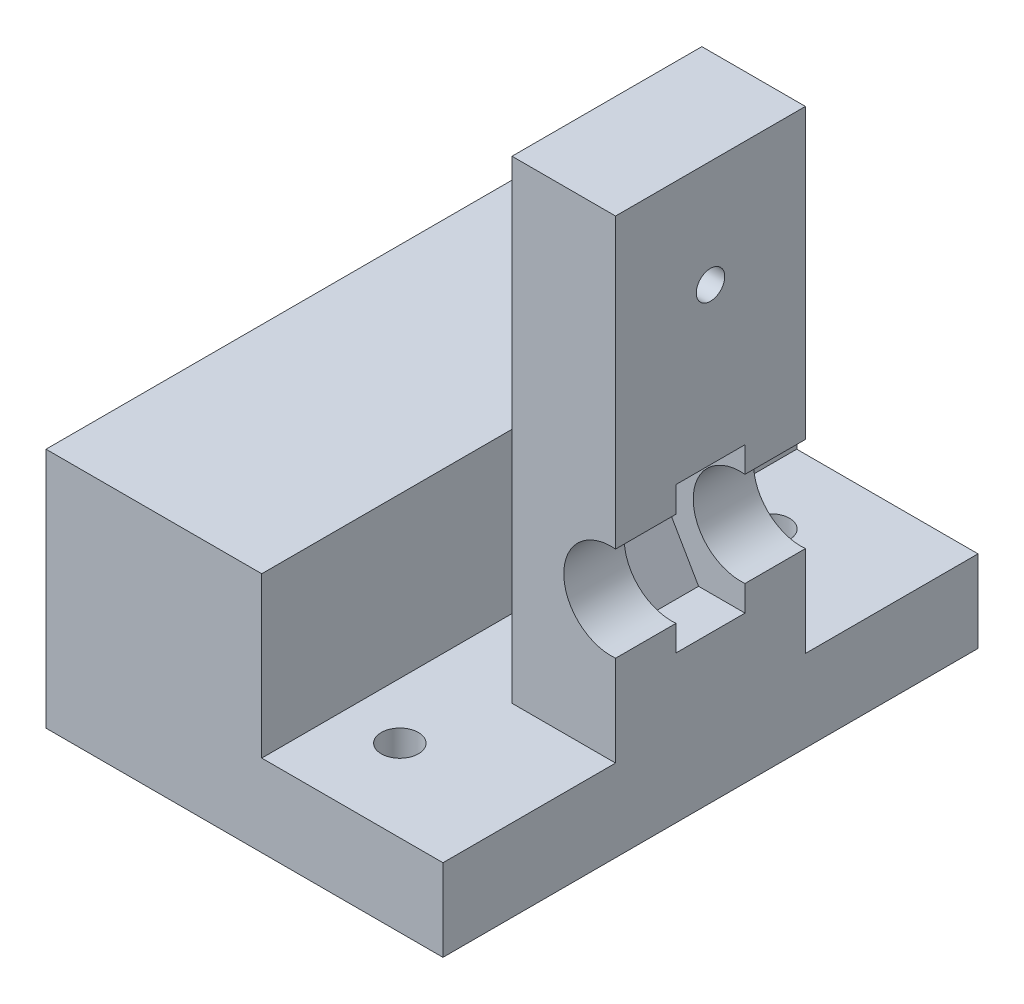
from build123d import *

# Parameters (mm, degrees)
SKETCH_1_W          = 23
SKETCH_1_H          = 64.4
EXTRUDE_1_DEPTH     = 8
SKETCH_3_W          = 23
SKETCH_3_H          = 64.4
SKETCH_3_R          = 5.5
EXTRUDE_2_DEPTH     = 7
SKETCH_4_W          = 23
SKETCH_4_H          = 64.4
SKETCH_4_R          = 5.5
EXTRUDE_3_DEPTH     = 7
SKETCH_5_R          = 1.65
CUT_EXTRUDE_1_DEPTH = 24
SKETCH_6_W          = 22
SKETCH_6_H          = 64.4
CUT_EXTRUDE_2_DEPTH = 11
EXTRUDE_4_DEPTH     = 9.5
SKETCH_8_R          = 2.15
CUT_EXTRUDE_3_DEPTH = 10.5
SKETCH_9_R          = 4.75
CUT_EXTRUDE_4_DEPTH = 3.5
SKETCH_10_W         = 25
SKETCH_10_H         = 62
EXTRUDE_5_DEPTH     = 18.5


with BuildPart() as part:
    # 草圖1 → 填料-伸長1 (new body)
    with BuildSketch(Plane.XY):
        with Locations((-0.36746988, -27.579314659)):
            Rectangle(SKETCH_1_W, SKETCH_1_H)
        Polygon((9.38974967, -34.279314659), (4.511139895, -25.829314659), (-5.246079654, -25.829314659), (-10.124689429, -34.279314659), (-5.246079654, -42.729314659), (4.511139895, -42.729314659), align=None, mode=Mode.SUBTRACT)
    extrude(amount=EXTRUDE_1_DEPTH)

    # 草圖3 → 填料-伸長2 (add)
    with BuildSketch(Plane.XY.offset(8)):
        with Locations((-0.36746988, -27.579314659)):
            Rectangle(SKETCH_3_W, SKETCH_3_H)
        with Locations((-0.36746988, -34.279314659)):
            Circle(SKETCH_3_R, mode=Mode.SUBTRACT)
    extrude(amount=EXTRUDE_2_DEPTH)

    # 草圖4 → 填料-伸長3 (add)
    with BuildSketch(Plane(origin=(0, 0, 0), x_dir=(-1, 0, 0), z_dir=(0, 0, -1))):
        with Locations((0.36746988, -27.579314659)):
            Rectangle(SKETCH_4_W, SKETCH_4_H)
        with Locations((0.36746988, -34.279314659)):
            Circle(SKETCH_4_R, mode=Mode.SUBTRACT)
    extrude(amount=EXTRUDE_3_DEPTH)

    # 草圖5 → 除料-伸長1 (cut, through all)
    with BuildSketch(Plane(origin=(11.13253012, 0, 0), x_dir=(0, 0, -1), z_dir=(1, 0, 0))):
        with Locations((-4, -7.779314659)):
            Circle(SKETCH_5_R)
    extrude(amount=-CUT_EXTRUDE_1_DEPTH, mode=Mode.SUBTRACT)

    # 草圖6 → 除料-伸長2 (cut)
    with BuildSketch(Plane(origin=(11.13253012, 0, 0), x_dir=(0, 0, -1), z_dir=(1, 0, 0))):
        with Locations((-4, -27.579314659)):
            Rectangle(SKETCH_6_W, SKETCH_6_H)
    extrude(amount=-CUT_EXTRUDE_2_DEPTH, mode=Mode.SUBTRACT)

    # 草圖7 → 填料-伸長4 (add)
    with BuildSketch(Plane.XZ.offset(59.779314659)):
        Polygon((0.13253012, 15), (0.13253012, 35), (-45.86746988, 35), (-45.86746988, -27), (0.13253012, -27), (0.13253012, -7), align=None)
    extrude(amount=-EXTRUDE_4_DEPTH)

    # 草圖8 → 除料-伸長3 (cut, through all)
    with BuildSketch(Plane(origin=(0, -50.279314659, 0), x_dir=(1, 0, 0), z_dir=(0, 1, 0))):
        with Locations((-14.36746988, 17.5)):
            Circle(SKETCH_8_R)
        with Locations((-14.36746988, -25.5)):
            Circle(SKETCH_8_R)
    extrude(amount=-CUT_EXTRUDE_3_DEPTH, mode=Mode.SUBTRACT)

    # 草圖9 → 除料-伸長4 (cut)
    with BuildSketch(Plane.XZ.offset(59.779314659)):
        with Locations((-34.06746988, 23.2)):
            Circle(SKETCH_9_R)
        with Locations((-34.06746988, -15.2)):
            Circle(SKETCH_9_R)
    extrude(amount=-CUT_EXTRUDE_4_DEPTH, mode=Mode.SUBTRACT)

    # 草圖10 → 填料-伸長5 (add)
    with BuildSketch(Plane(origin=(0, -50.279314659, 0), x_dir=(1, 0, 0), z_dir=(0, 1, 0))):
        with Locations((-33.36746988, -4)):
            Rectangle(SKETCH_10_W, SKETCH_10_H)
    extrude(amount=EXTRUDE_5_DEPTH)


solid = part.part
